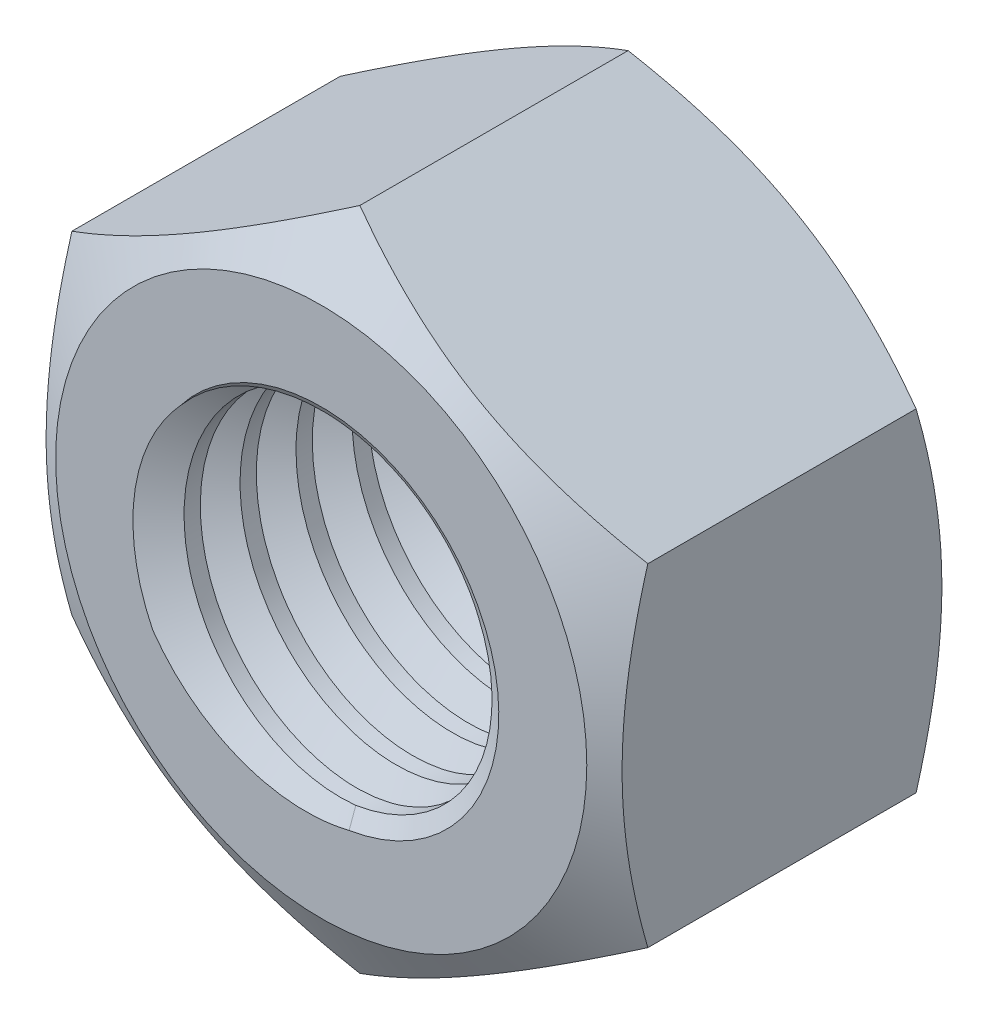
from build123d import *
from OCP.BRepFilletAPI import BRepFilletAPI_MakeChamfer

# Parameters (mm, degrees)
SZKIC1_R                                     = 5.05
DODANIE_WYCI_GNI_CIE1_DEPTH                  = 10.8
SZKIC2_OUTSIDE_W                             = 89.934
SZKIC2_OUTSIDE_H                             = 92.718
SZKIC2_OUTSIDE_R                             = 8.3
WYTNIJ_WYCI_GNI_CIE1_DEPTH                   = 18.482562741
WYTNIJ_WYCI_GNI_CIE1_DRAFT                   = -60
SZKIC3_OUTSIDE_W                             = 89.934
SZKIC3_OUTSIDE_H                             = 92.718
SZKIC3_OUTSIDE_R                             = 8.3
WYTNIJ_WYCI_GNI_CIE3_DEPTH                   = 18.482562741
WYTNIJ_WYCI_GNI_CIE3_DRAFT                   = -60
SFAZOWANIE2_SIZE                             = 0.5
SFAZOWANIE2_SIZE2                            = 0.288675135
WYCI_CIE_WYCI_GNI_CIE_PO_CIE_CE4_PITCH       = 1.75
WYCI_CIE_WYCI_GNI_CIE_PO_CIE_CE4_HEIGHT      = 13
WYCI_CIE_WYCI_GNI_CIE_PO_CIE_CE4_RADIUS      = 5.05
WYCI_CIE_WYCI_GNI_CIE_PO_CIE_CE4_START_ANGLE = 180


with BuildPart() as part:
    # Szkic1 → Dodanie-wyciągnięcie1 (new body)
    with BuildSketch(Plane.XY):
        Polygon((0, 10.392304845), (-9, 5.196152423), (-9, -5.196152423), (0, -10.392304845), (9, -5.196152423), (9, 5.196152423), align=None)
        with Locations(Location((0, 0, 0), (0, 0, 180))):
            Circle(SZKIC1_R, mode=Mode.SUBTRACT)
    extrude(amount=DODANIE_WYCI_GNI_CIE1_DEPTH)


with BuildPart() as wytnij_wyci_gni_cie1_tool:
    # Szkic2 outside → Wytnij-wyciągnięcie1 (with draft: the straight prism first)
    with BuildSketch(Plane.XY.offset(10.8)):
        Rectangle(SZKIC2_OUTSIDE_W, SZKIC2_OUTSIDE_H)
        Circle(SZKIC2_OUTSIDE_R, mode=Mode.SUBTRACT)
    extrude(amount=-WYTNIJ_WYCI_GNI_CIE1_DEPTH)
    # Wytnij-wyciągnięcie1: the draft: its side faces are tilted about the plane it starts from
    wytnij_wyci_gni_cie1_sides = [wytnij_wyci_gni_cie1_tool.faces().sort_by_distance(p)[0] for p in [
        (0, -46.359, 1.558718629),
        (44.967, 0, 1.558718629),
        (0, 46.359, 1.558718629),
        (-44.967, 0, 1.558718629),
        (-8.3, 0, 1.558718629),
    ]]
    draft(wytnij_wyci_gni_cie1_sides, Plane.XY.offset(10.8), WYTNIJ_WYCI_GNI_CIE1_DRAFT)


with BuildPart() as part_1:
    add(part.part)

    # Wytnij-wyciągnięcie1: cut by wytnij_wyci_gni_cie1_tool
    add(wytnij_wyci_gni_cie1_tool.part, mode=Mode.SUBTRACT)


with BuildPart() as wytnij_wyci_gni_cie3_tool:
    # Szkic3 outside → Wytnij-wyciągnięcie3 (with draft: the straight prism first)
    with BuildSketch(Plane(origin=(0, 0, 0), x_dir=(-1, 0, 0), z_dir=(0, 0, -1))):
        Rectangle(SZKIC3_OUTSIDE_W, SZKIC3_OUTSIDE_H)
        Circle(SZKIC3_OUTSIDE_R, mode=Mode.SUBTRACT)
    extrude(amount=-WYTNIJ_WYCI_GNI_CIE3_DEPTH)
    # Wytnij-wyciągnięcie3: the draft: its side faces are tilted about the plane it starts from
    wytnij_wyci_gni_cie3_sides = [wytnij_wyci_gni_cie3_tool.faces().sort_by_distance(p)[0] for p in [
        (0, -46.359, 9.241281371),
        (-44.967, 0, 9.241281371),
        (0, 46.359, 9.241281371),
        (44.967, 0, 9.241281371),
        (8.3, 0, 9.241281371),
    ]]
    draft(wytnij_wyci_gni_cie3_sides, Plane(origin=(0, 0, 0), x_dir=(-1, 0, 0), z_dir=(0, 0, -1)), WYTNIJ_WYCI_GNI_CIE3_DRAFT)


with BuildPart() as part_2:
    add(part_1.part)

    # Wytnij-wyciągnięcie3: cut by wytnij_wyci_gni_cie3_tool
    add(wytnij_wyci_gni_cie3_tool.part, mode=Mode.SUBTRACT)

    # Sfazowanie2: one chamfer whose edges measure the first distance from different faces: ONE call of the kernel's chamfer builder (chamfer() names one face for all edges)
    sfazowanie2_edges_1 = [part_2.edges().sort_by_distance(p)[0] for p in [
        (5.05, 0, 0),
    ]]
    sfazowanie2_side_1 = [part_2.faces().sort_by_distance(p)[0] for p in [
        (5.05, 0, 5.4),
    ]]
    sfazowanie2_edges_2 = [part_2.edges().sort_by_distance(p)[0] for p in [
        (5.05, 0, 10.8),
    ]]
    sfazowanie2_side_2 = [part_2.faces().sort_by_distance(p)[0] for p in [
        (-8.065240549, 0, 10.8),
    ]]
    sfazowanie2 = BRepFilletAPI_MakeChamfer(part_2.part.solid().wrapped)
    for e in sfazowanie2_edges_1:
        sfazowanie2.Add(SFAZOWANIE2_SIZE, SFAZOWANIE2_SIZE2, e.wrapped, sfazowanie2_side_1[0].wrapped)  # the first distance lies on this face
    for e in sfazowanie2_edges_2:
        sfazowanie2.Add(SFAZOWANIE2_SIZE, SFAZOWANIE2_SIZE2, e.wrapped, sfazowanie2_side_2[0].wrapped)  # the first distance lies on this face
    add(Compound.cast(sfazowanie2.Shape()), mode=Mode.REPLACE)

    # Wycięcie-wyciągnięcie po ścieżce4: sweep along a helix
    with BuildLine() as wyci_cie_wyci_gni_cie_po_cie_ce4_path:
        add(Helix(WYCI_CIE_WYCI_GNI_CIE_PO_CIE_CE4_PITCH, WYCI_CIE_WYCI_GNI_CIE_PO_CIE_CE4_HEIGHT, WYCI_CIE_WYCI_GNI_CIE_PO_CIE_CE4_RADIUS, center=(0, 0, 0), direction=(0, 0, 1), mode=Mode.PRIVATE).rotate(Axis((0, 0, 0), (0, 0, 1)), WYCI_CIE_WYCI_GNI_CIE_PO_CIE_CE4_START_ANGLE))
    # Szkic9 → Wycięcie-wyciągnięcie po ścieżce4 (sweep, cut)
    with BuildSketch(Plane(origin=(0, 0, 0), x_dir=(1, 0, 0), z_dir=(0, 1, 0))):
        Polygon((-6.125, 1.6), (-4.5125, 0.669022691), (-4.5125, 2.530977309), align=None)
    sweep(path=wyci_cie_wyci_gni_cie_po_cie_ce4_path.line, is_frenet=True, mode=Mode.SUBTRACT)


solid = part_2.part
